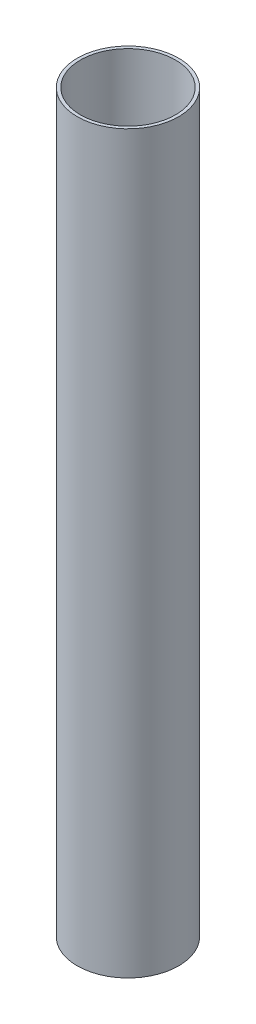
from build123d import *

# Parameters (mm, degrees)
SKETCH_1_R      = 16
SKETCH_1_R_2    = 15
EXTRUDE_1_DEPTH = 232


with BuildPart() as part:
    # 草图1 → 凸台-拉伸1 (new body)
    with BuildSketch(Plane(origin=(0, 0, 0), x_dir=(1, 0, 0), z_dir=(0, 1, 0))):
        Circle(SKETCH_1_R)
        Circle(SKETCH_1_R_2, mode=Mode.SUBTRACT)
    extrude(amount=EXTRUDE_1_DEPTH)


solid = part.part
